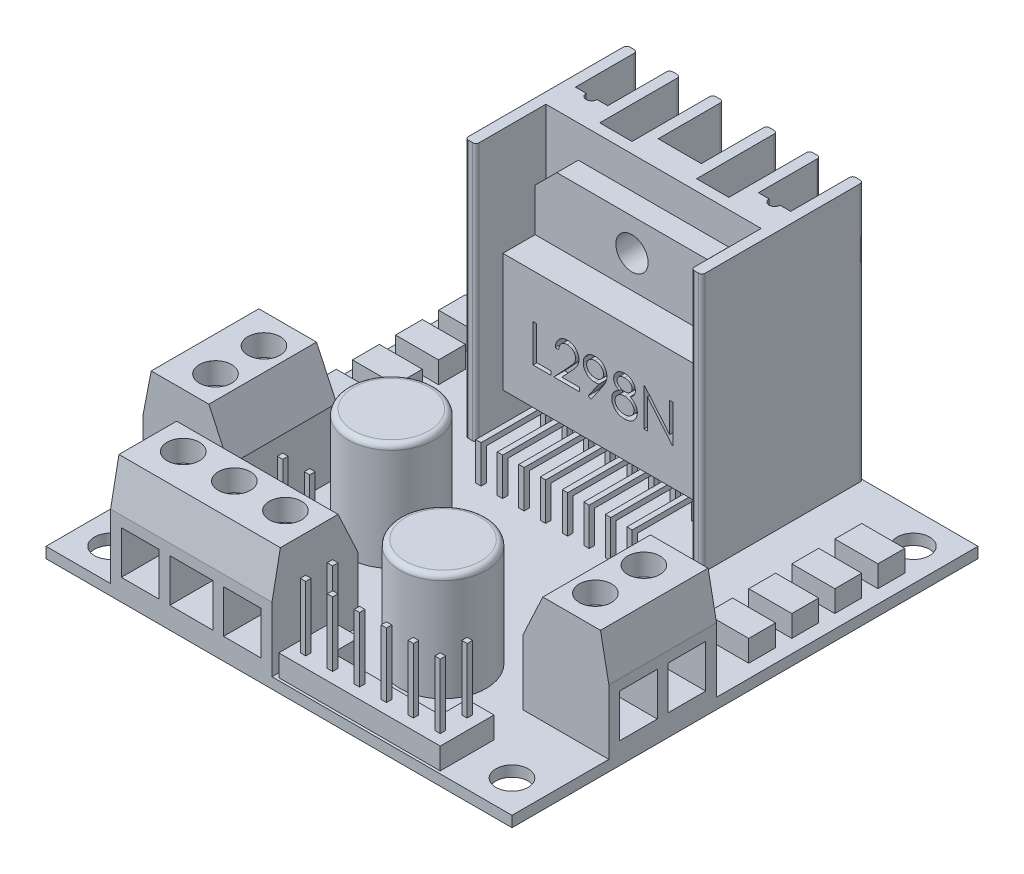
from build123d import *

# Parameters (mm, degrees)
CROQUIS1_W               = 43.3
CROQUIS1_H               = 43.3
CROQUIS1_R               = 1.5
SALIENTE_EXTRUIR1_DEPTH  = 1
CROQUIS2_W               = 1
CROQUIS2_H               = 1
CROQUIS2_H_2             = 6.5
CROQUIS2_W_2             = 3
CROQUIS2_W_3             = 2
CROQUIS2_H_3             = 1.435307759
SALIENTE_EXTRUIR2_DEPTH  = 24
CROQUIS3_W               = 8
CROQUIS3_H               = 10
SALIENTE_EXTRUIR3_DEPTH  = 10
CHAFL_N1_SIZE            = 4
CHAFL_N1_SIZE2           = 1.865230633
CHAFL_N2_SIZE            = 4
CHAFL_N2_SIZE2           = 1.865230633
CHAFL_N3_SIZE            = 4
CHAFL_N3_SIZE2           = 0.777521237
CHAFL_N4_SIZE            = 4
CHAFL_N4_SIZE2           = 0.777521237
CROQUIS4_W               = 15
CROQUIS4_H               = 8
SALIENTE_EXTRUIR4_DEPTH  = 10
CHAFL_N5_SIZE            = 4
CHAFL_N5_SIZE2           = 0.777521237
CHAFL_N6_SIZE            = 4
CHAFL_N6_SIZE2           = 1.865230633
CROQUIS5_W               = 4
CROQUIS5_H               = 2.5
SALIENTE_EXTRUIR5_DEPTH  = 2
CROQUIS6_R               = 4
SALIENTE_EXTRUIR6_DEPTH  = 10
REDONDEO1_R              = 0.5
SALIENTE_EXTRUIR7_DEPTH  = 2
CROQUIS8_W               = 2.5
CROQUIS8_H               = 2.5
SALIENTE_EXTRUIR8_DEPTH  = 2
CROQUIS9_W               = 0.25
CROQUIS9_H               = 0.25
CROQUIS9_H_2             = 0.5
CROQUIS9_W_2             = 0.5
SALIENTE_EXTRUIR9_DEPTH  = 6
CROQUIS10_W              = 0.5
CROQUIS10_H              = 0.5
SALIENTE_EXTRUIR10_DEPTH = 6
CROQUIS11_W              = 9
CROQUIS11_H              = 10
SALIENTE_EXTRUIR11_DEPTH = 5
CORTAR_EXTRUIR1_DEPTH    = 3
CROQUIS13_W              = 0.5
CROQUIS13_H              = 0.5
SALIENTE_EXTRUIR12_DEPTH = 1
CROQUIS14_W              = 0.5
CROQUIS14_H              = 0.5
SALIENTE_EXTRUIR13_DEPTH = 7
CROQUIS15_W              = 0.5
CROQUIS15_H              = 0.5
SALIENTE_EXTRUIR14_DEPTH = 4
CROQUIS16_W              = 0.5
CROQUIS16_H              = 0.5
SALIENTE_EXTRUIR15_DEPTH = 4
CORTAR_EXTRUIR2_DEPTH    = 1
CROQUIS18_R              = 1.5
CORTAR_EXTRUIR3_DEPTH    = 11.5
CROQUIS19_W              = 3.5
CROQUIS19_H              = 4
CORTAR_EXTRUIR4_DEPTH    = 4
CROQUIS20_W              = 3.5
CROQUIS20_H              = 4
CROQUIS20_W_2            = 4
CORTAR_EXTRUIR5_DEPTH    = 4
CROQUIS21_W              = 3.5
CROQUIS21_H              = 4
CORTAR_EXTRUIR6_DEPTH    = 4
CROQUIS22_R              = 1.5
CORTAR_EXTRUIR7_DEPTH    = 2
REDONDEO2_R              = 0.3


with BuildPart() as part:
    # Croquis1 → Saliente-Extruir1 (new body)
    with BuildSketch(Plane(origin=(0, 0, 0), x_dir=(1, 0, 0), z_dir=(0, 1, 0))):
        with Locations((-21.65, -21.65)):
            Rectangle(CROQUIS1_W, CROQUIS1_H)
        with Locations((-40.3, -3)):
            Circle(CROQUIS1_R, mode=Mode.SUBTRACT)
        with Locations((-3, -3)):
            Circle(CROQUIS1_R, mode=Mode.SUBTRACT)
        with Locations((-40.3, -40.3)):
            Circle(CROQUIS1_R, mode=Mode.SUBTRACT)
        with Locations((-3, -40.3)):
            Circle(CROQUIS1_R, mode=Mode.SUBTRACT)
    extrude(amount=SALIENTE_EXTRUIR1_DEPTH)

    # Croquis2 → Saliente-Extruir2 (add)
    with BuildSketch(Plane(origin=(0, 1, 0), x_dir=(-1, 0, 0), z_dir=(0, 1, 0))):
        Polygon((31.65, 5.75316787), (31.65, 0), (32.65, 0), (32.65, 7.5), (31.65, 7.5), align=None)
        with Locations((32.15, 8)):
            Rectangle(CROQUIS2_W, CROQUIS2_H)
        with Locations((32.15, 11.75)):
            Rectangle(CROQUIS2_W, CROQUIS2_H_2)
        with Locations((30.15, 8)):
            Rectangle(CROQUIS2_W_2, CROQUIS2_H)
        with Locations((28.15, 8)):
            Rectangle(CROQUIS2_W, CROQUIS2_H)
        with BuildLine():
            Line((31.65, 7.5), (28.65, 7.5))
            Line((28.65, 7.5), (28.65, 5.75316787))
            Line((28.65, 5.75316787), (29.645779613, 5.75316787))
            ThreePointArc((29.645779613, 5.75316787), (30.15, 6.257388257), (30.654220387, 5.75316787))
            Line((30.654220387, 5.75316787), (31.65, 5.75316787))
            Line((31.65, 5.75316787), (31.65, 7.5))
        make_face()
        with Locations((22.65, 6.782346121)):
            Rectangle(CROQUIS2_W_3, CROQUIS2_H_3)
        with Locations((20.65, 6.782346121)):
            Rectangle(CROQUIS2_W_3, CROQUIS2_H_3)
        Polygon((23.65, 6.064692241), (23.65, 0), (24.65, 0), (24.65, 7.5), (23.65, 7.5), align=None)
        Polygon((27.65, 7.5), (27.65, 0), (28.65, 0), (28.65, 5.75316787), (28.65, 7.5), align=None)
        with Locations((26.15, 8)):
            Rectangle(CROQUIS2_W_2, CROQUIS2_H)
        with Locations((24.15, 8)):
            Rectangle(CROQUIS2_W, CROQUIS2_H)
        with Locations((22.65, 8)):
            Rectangle(CROQUIS2_W_3, CROQUIS2_H)
        with Locations((20.65, 8)):
            Rectangle(CROQUIS2_W_3, CROQUIS2_H)
        with Locations((19.15, 8)):
            Rectangle(CROQUIS2_W, CROQUIS2_H)
        Polygon((18.65, 7.5), (18.65, 0), (19.65, 0), (19.65, 6.064692241), (19.65, 7.5), align=None)
        with Locations((17.15, 8)):
            Rectangle(CROQUIS2_W_2, CROQUIS2_H)
        with Locations((15.15, 8)):
            Rectangle(CROQUIS2_W, CROQUIS2_H)
        with Locations((13.15, 8)):
            Rectangle(CROQUIS2_W_2, CROQUIS2_H)
        with Locations((11.15, 11.75)):
            Rectangle(CROQUIS2_W, CROQUIS2_H_2)
        with Locations((11.15, 8)):
            Rectangle(CROQUIS2_W, CROQUIS2_H)
        Polygon((10.65, 7.5), (10.65, 0), (11.65, 0), (11.65, 5.75316787), (11.65, 7.5), align=None)
        with BuildLine():
            Line((14.65, 7.5), (11.65, 7.5))
            Line((11.65, 7.5), (11.65, 5.75316787))
            Line((11.65, 5.75316787), (12.645779613, 5.75316787))
            ThreePointArc((12.645779613, 5.75316787), (13.15, 6.257388257), (13.654220387, 5.75316787))
            Line((13.654220387, 5.75316787), (14.65, 5.75316787))
            Line((14.65, 5.75316787), (14.65, 7.5))
        make_face()
        Polygon((14.65, 5.75316787), (14.65, 0), (15.65, 0), (15.65, 7.5), (14.65, 7.5), align=None)
    extrude(amount=SALIENTE_EXTRUIR2_DEPTH)

    # Croquis3 → Saliente-Extruir3 (add)
    with BuildSketch(Plane(origin=(0, 1, 0), x_dir=(-1, 0, 0), z_dir=(0, 1, 0))):
        with Locations((39.3, 29.3)):
            Rectangle(CROQUIS3_W, CROQUIS3_H)
        with Locations((4, 29.3)):
            Rectangle(CROQUIS3_W, CROQUIS3_H)
    extrude(amount=SALIENTE_EXTRUIR3_DEPTH)

    # Chaflán1
    chafl_n1_edges = [part.edges().sort_by_distance(p)[0] for p in [
        (-35.3, 11, 29.3),
    ]]
    chafl_n1_side = [part.faces().sort_by_distance(p)[0] for p in [
        (-35.3, 6, 29.3),
    ]]
    chamfer(chafl_n1_edges, length=CHAFL_N1_SIZE, length2=CHAFL_N1_SIZE2, reference=chafl_n1_side[0])

    # Chaflán2
    chafl_n2_edges = [part.edges().sort_by_distance(p)[0] for p in [
        (-8, 11, 29.3),
    ]]
    chafl_n2_side = [part.faces().sort_by_distance(p)[0] for p in [
        (-8, 6, 29.3),
    ]]
    chamfer(chafl_n2_edges, length=CHAFL_N2_SIZE, length2=CHAFL_N2_SIZE2, reference=chafl_n2_side[0])

    # Chaflán3
    chafl_n3_edges = [part.edges().sort_by_distance(p)[0] for p in [
        (0, 11, 29.3),
    ]]
    chafl_n3_side = [part.faces().sort_by_distance(p)[0] for p in [
        (0, 4.338101884, 26.988450803),
    ]]
    chamfer(chafl_n3_edges, length=CHAFL_N3_SIZE, length2=CHAFL_N3_SIZE2, reference=chafl_n3_side[0])

    # Chaflán4
    chafl_n4_edges = [part.edges().sort_by_distance(p)[0] for p in [
        (-43.3, 11, 29.3),
    ]]
    chafl_n4_side = [part.faces().sort_by_distance(p)[0] for p in [
        (-43.3, 4.338101884, 26.988450803),
    ]]
    chamfer(chafl_n4_edges, length=CHAFL_N4_SIZE, length2=CHAFL_N4_SIZE2, reference=chafl_n4_side[0])

    # Croquis4 → Saliente-Extruir4 (add)
    with BuildSketch(Plane(origin=(0, 1, 0), x_dir=(-1, 0, 0), z_dir=(0, 1, 0))):
        with Locations((29.8, 39.3)):
            Rectangle(CROQUIS4_W, CROQUIS4_H)
    extrude(amount=SALIENTE_EXTRUIR4_DEPTH)

    # Chaflán5
    chafl_n5_edges = [part.edges().sort_by_distance(p)[0] for p in [
        (-29.8, 11, 43.3),
    ]]
    chafl_n5_side = [part.faces().sort_by_distance(p)[0] for p in [
        (-27.97436627, 4.767977237, 43.3),
    ]]
    chamfer(chafl_n5_edges, length=CHAFL_N5_SIZE, length2=CHAFL_N5_SIZE2, reference=chafl_n5_side[0])

    # Chaflán6
    chafl_n6_edges = [part.edges().sort_by_distance(p)[0] for p in [
        (-29.8, 11, 35.3),
    ]]
    chafl_n6_side = [part.faces().sort_by_distance(p)[0] for p in [
        (-29.8, 6, 35.3),
    ]]
    chamfer(chafl_n6_edges, length=CHAFL_N6_SIZE, length2=CHAFL_N6_SIZE2, reference=chafl_n6_side[0])

    # Croquis5 → Saliente-Extruir5 (add)
    with BuildSketch(Plane(origin=(0, 1, 0), x_dir=(-1, 0, 0), z_dir=(0, 1, 0))):
        with Locations((40.060783052, 10.814133786)):
            Rectangle(CROQUIS5_W, CROQUIS5_H)
        with Locations((40.060783052, 6.814133786)):
            Rectangle(CROQUIS5_W, CROQUIS5_H)
        with Locations((40.060783052, 14.814133786)):
            Rectangle(CROQUIS5_W, CROQUIS5_H)
        with Locations((40.060783052, 18.814133786)):
            Rectangle(CROQUIS5_W, CROQUIS5_H)
        with Locations((3.239216948, 6.814133786)):
            Rectangle(CROQUIS5_W, CROQUIS5_H)
        with Locations((3.239216948, 10.814133786)):
            Rectangle(CROQUIS5_W, CROQUIS5_H)
        with Locations((3.239216948, 14.814133786)):
            Rectangle(CROQUIS5_W, CROQUIS5_H)
        with Locations((3.239216948, 18.814133786)):
            Rectangle(CROQUIS5_W, CROQUIS5_H)
    extrude(amount=SALIENTE_EXTRUIR5_DEPTH)

    # Croquis6 → Saliente-Extruir6 (add)
    with BuildSketch(Plane(origin=(0, 1, 0), x_dir=(-1, 0, 0), z_dir=(0, 1, 0))):
        with Locations((28.3, 26.210008209)):
            Circle(CROQUIS6_R)
        with Locations((15.406645961, 34.3)):
            Circle(CROQUIS6_R)
    extrude(amount=SALIENTE_EXTRUIR6_DEPTH)

    # Redondeo1
    redondeo1_edges = [part.edges().sort_by_distance(p)[0] for p in [
        (-24.3, 11, 26.210008209),
        (-11.406645961, 11, 34.3),
    ]]
    fillet(redondeo1_edges, radius=REDONDEO1_R)

    # Croquis7 → Saliente-Extruir7 (add)
    with BuildSketch(Plane(origin=(0, 1, 0), x_dir=(-1, 0, 0), z_dir=(0, 1, 0))):
        Polygon((19.407725127, 40.559550143), (19.407725127, 38.059550143), (21.907725127, 38.059550143), (21.907725127, 40.559550143), (21.907725127, 43.059550143), (6.907725127, 43.059550143), (6.907725127, 38.059550143), (9.407725127, 38.059550143), (9.407725127, 40.559550143), align=None)
    extrude(amount=SALIENTE_EXTRUIR7_DEPTH)

    # Croquis8 → Saliente-Extruir8 (add)
    with BuildSketch(Plane(origin=(0, 1, 0), x_dir=(-1, 0, 0), z_dir=(0, 1, 0))):
        with Locations((29.05, 33.05)):
            Rectangle(CROQUIS8_W, CROQUIS8_H)
        with Locations((31.55, 33.05)):
            Rectangle(CROQUIS8_W, CROQUIS8_H)
    extrude(amount=SALIENTE_EXTRUIR8_DEPTH)

    # Croquis9 → Saliente-Extruir9 (add)
    with BuildSketch(Plane(origin=(0, 3, 0), x_dir=(-1, 0, 0), z_dir=(0, 1, 0))):
        with Locations((20.532725127, 41.934550143)):
            Rectangle(CROQUIS9_W, CROQUIS9_H)
        with Locations((20.532725127, 41.684550143)):
            Rectangle(CROQUIS9_W, CROQUIS9_H)
        with Locations((20.782725127, 41.934550143)):
            Rectangle(CROQUIS9_W, CROQUIS9_H)
        with Locations((20.782725127, 41.684550143)):
            Rectangle(CROQUIS9_W, CROQUIS9_H)
        with Locations((20.532725127, 39.309550143)):
            Rectangle(CROQUIS9_W, CROQUIS9_H_2)
        with Locations((20.782725127, 39.309550143)):
            Rectangle(CROQUIS9_W, CROQUIS9_H_2)
        with Locations((18.157725127, 41.684550143)):
            Rectangle(CROQUIS9_W_2, CROQUIS9_H)
        with Locations((18.157725127, 41.934550143)):
            Rectangle(CROQUIS9_W_2, CROQUIS9_H)
        with Locations((15.657725127, 41.684550143)):
            Rectangle(CROQUIS9_W_2, CROQUIS9_H)
        with Locations((15.657725127, 41.934550143)):
            Rectangle(CROQUIS9_W_2, CROQUIS9_H)
        with Locations((13.157725127, 41.934550143)):
            Rectangle(CROQUIS9_W_2, CROQUIS9_H)
        with Locations((13.157725127, 41.684550143)):
            Rectangle(CROQUIS9_W_2, CROQUIS9_H)
        with Locations((10.657725127, 41.934550143)):
            Rectangle(CROQUIS9_W_2, CROQUIS9_H)
        with Locations((10.657725127, 41.684550143)):
            Rectangle(CROQUIS9_W_2, CROQUIS9_H)
        with Locations((8.032725127, 41.934550143)):
            Rectangle(CROQUIS9_W, CROQUIS9_H)
        with Locations((8.032725127, 41.684550143)):
            Rectangle(CROQUIS9_W, CROQUIS9_H)
        with Locations((8.282725127, 41.684550143)):
            Rectangle(CROQUIS9_W, CROQUIS9_H)
        with Locations((8.282725127, 41.934550143)):
            Rectangle(CROQUIS9_W, CROQUIS9_H)
        with Locations((8.032725127, 39.309550143)):
            Rectangle(CROQUIS9_W, CROQUIS9_H_2)
        with Locations((8.282725127, 39.309550143)):
            Rectangle(CROQUIS9_W, CROQUIS9_H_2)
    extrude(amount=SALIENTE_EXTRUIR9_DEPTH)

    # Croquis10 → Saliente-Extruir10 (add)
    with BuildSketch(Plane(origin=(0, 3, 0), x_dir=(1, 0, 0), z_dir=(0, 1, 0))):
        with Locations((-29.05, -33.05)):
            Rectangle(CROQUIS10_W, CROQUIS10_H)
        with Locations((-31.55, -33.05)):
            Rectangle(CROQUIS10_W, CROQUIS10_H)
    extrude(amount=SALIENTE_EXTRUIR10_DEPTH)

    # Croquis11 → Saliente-Extruir11 (add)
    with BuildSketch(Plane.XY.offset(8.5)):
        Polygon((-21.65, 15), (-21.65, 22), (-28.637466442, 22), (-30.65, 19.987466442), (-30.65, 15), align=None)
        Polygon((-14.662533558, 22), (-21.65, 22), (-21.65, 15), (-12.65, 15), (-12.65, 19.987466442), align=None)
        with Locations((-26.15, 10)):
            Rectangle(CROQUIS11_W, CROQUIS11_H)
        with Locations((-17.15, 10)):
            Rectangle(CROQUIS11_W, CROQUIS11_H)
    extrude(amount=SALIENTE_EXTRUIR11_DEPTH)

    # Croquis12 → Cortar-Extruir1 (cut)
    with BuildSketch(Plane.XY.offset(13.5)):
        Polygon((-14.662533558, 22), (-28.637466442, 22), (-30.65, 19.987466442), (-30.65, 16), (-12.65, 16), (-12.65, 19.987466442), align=None)
    extrude(amount=-CORTAR_EXTRUIR1_DEPTH, mode=Mode.SUBTRACT)

    # Croquis13 → Saliente-Extruir12 (add)
    with BuildSketch(Plane.XZ.offset(-5)):
        with Locations((-28.173070454, 11)):
            Rectangle(CROQUIS13_W, CROQUIS13_H)
        with Locations((-29.173070454, 11)):
            Rectangle(CROQUIS13_W, CROQUIS13_H)
        with Locations((-27.173070454, 11)):
            Rectangle(CROQUIS13_W, CROQUIS13_H)
        with Locations((-26.173070454, 11)):
            Rectangle(CROQUIS13_W, CROQUIS13_H)
        with Locations((-25.173070454, 11)):
            Rectangle(CROQUIS13_W, CROQUIS13_H)
        with Locations((-24.173070454, 11)):
            Rectangle(CROQUIS13_W, CROQUIS13_H)
        with Locations((-23.173070454, 11)):
            Rectangle(CROQUIS13_W, CROQUIS13_H)
        with Locations((-22.173070454, 11)):
            Rectangle(CROQUIS13_W, CROQUIS13_H)
        with Locations((-21.126929546, 11)):
            Rectangle(CROQUIS13_W, CROQUIS13_H)
        with Locations((-20.126929546, 11)):
            Rectangle(CROQUIS13_W, CROQUIS13_H)
        with Locations((-19.126929546, 11)):
            Rectangle(CROQUIS13_W, CROQUIS13_H)
        with Locations((-18.126929546, 11)):
            Rectangle(CROQUIS13_W, CROQUIS13_H)
        with Locations((-17.126929546, 11)):
            Rectangle(CROQUIS13_W, CROQUIS13_H)
        with Locations((-16.126929546, 11)):
            Rectangle(CROQUIS13_W, CROQUIS13_H)
        with Locations((-15.126929546, 11)):
            Rectangle(CROQUIS13_W, CROQUIS13_H)
        with Locations((-14.126929546, 11)):
            Rectangle(CROQUIS13_W, CROQUIS13_H)
    extrude(amount=SALIENTE_EXTRUIR12_DEPTH)

    # Croquis14 → Saliente-Extruir13 (add)
    with BuildSketch(Plane.XY.offset(11.25)):
        with Locations((-14.126929546, 4.25)):
            Rectangle(CROQUIS14_W, CROQUIS14_H)
        with Locations((-16.126929546, 4.25)):
            Rectangle(CROQUIS14_W, CROQUIS14_H)
        with Locations((-18.126929546, 4.25)):
            Rectangle(CROQUIS14_W, CROQUIS14_H)
        with Locations((-20.126929546, 4.25)):
            Rectangle(CROQUIS14_W, CROQUIS14_H)
        with Locations((-22.173070454, 4.25)):
            Rectangle(CROQUIS14_W, CROQUIS14_H)
        with Locations((-24.173070454, 4.25)):
            Rectangle(CROQUIS14_W, CROQUIS14_H)
        with Locations((-26.173070454, 4.25)):
            Rectangle(CROQUIS14_W, CROQUIS14_H)
        with Locations((-28.173070454, 4.25)):
            Rectangle(CROQUIS14_W, CROQUIS14_H)
    extrude(amount=SALIENTE_EXTRUIR13_DEPTH)

    # Croquis15 → Saliente-Extruir14 (add)
    with BuildSketch(Plane.XZ):
        with Locations((-28.173070454, 18)):
            Rectangle(CROQUIS15_W, CROQUIS15_H)
        with Locations((-26.173070454, 18)):
            Rectangle(CROQUIS15_W, CROQUIS15_H)
        with Locations((-24.173070454, 18)):
            Rectangle(CROQUIS15_W, CROQUIS15_H)
        with Locations((-22.173070454, 18)):
            Rectangle(CROQUIS15_W, CROQUIS15_H)
        with Locations((-20.126929546, 18)):
            Rectangle(CROQUIS15_W, CROQUIS15_H)
        with Locations((-18.126929546, 18)):
            Rectangle(CROQUIS15_W, CROQUIS15_H)
        with Locations((-16.126929546, 18)):
            Rectangle(CROQUIS15_W, CROQUIS15_H)
        with Locations((-14.126929546, 18)):
            Rectangle(CROQUIS15_W, CROQUIS15_H)
    extrude(amount=-SALIENTE_EXTRUIR14_DEPTH)

    # Croquis16 → Saliente-Extruir15 (add)
    with BuildSketch(Plane.XZ):
        with Locations((-29.173070454, 11)):
            Rectangle(CROQUIS16_W, CROQUIS16_H)
        with Locations((-27.173070454, 11)):
            Rectangle(CROQUIS16_W, CROQUIS16_H)
        with Locations((-25.173070454, 11)):
            Rectangle(CROQUIS16_W, CROQUIS16_H)
        with Locations((-23.173070454, 11)):
            Rectangle(CROQUIS16_W, CROQUIS16_H)
        with Locations((-21.126929546, 11)):
            Rectangle(CROQUIS16_W, CROQUIS16_H)
        with Locations((-19.126929546, 11)):
            Rectangle(CROQUIS16_W, CROQUIS16_H)
        with Locations((-17.126929546, 11)):
            Rectangle(CROQUIS16_W, CROQUIS16_H)
        with Locations((-15.126929546, 11)):
            Rectangle(CROQUIS16_W, CROQUIS16_H)
    extrude(amount=-SALIENTE_EXTRUIR15_DEPTH)

    # Croquis17 → Cortar-Extruir2 (cut)
    with BuildSketch(Plane.XY.offset(13.5)):
        Polygon((-27.846931762, 11.915865738), (-27.532829198, 11.915865738), (-27.532829198, 8.774840097), (-26.186675351, 8.774840097), (-26.186675351, 8.415865738), (-27.846931762, 8.415865738), align=None)
        with BuildLine():
            Line((-25.468726633, 10.838942661), (-25.782829198, 10.838942661))
            add(Edge.make_bspline(
                [(-25.782829198, 10.838942661), (-25.780782045, 10.880613549), (-25.77676149, 10.962454063), (-25.757933201, 11.08177797), (-25.730992324, 11.195832768), (-25.69290087, 11.303702682), (-25.645594592, 11.40634149), (-25.588864565, 11.503341505), (-25.521670714, 11.594332694), (-25.44546398, 11.678471537), (-25.362695341, 11.755659108), (-25.273389402, 11.822314351), (-25.179544374, 11.878632022), (-25.081444976, 11.925713264), (-24.977984412, 11.96105311), (-24.870101554, 11.98727475), (-24.757322418, 12.003051095), (-24.680482396, 12.004746881), (-24.641402915, 12.005609328)],
                knots=[0, 0, 0, 0, 0.000125083, 0.00024566, 0.000361805, 0.000476223, 0.000588214, 0.000700404, 0.000812728, 0.00092691, 0.001040529, 0.001151727, 0.001260545, 0.001368429, 0.001477521, 0.001587884, 0.001701119, 0.00181831, 0.00181831, 0.00181831, 0.00181831], degree=3))
            add(Edge.make_bspline(
                [(-24.641402915, 12.005609328), (-24.603024841, 12.004710871), (-24.527613297, 12.002945436), (-24.417551282, 11.987784407), (-24.312773988, 11.964038815), (-24.213486221, 11.930723399), (-24.120480157, 11.885938972), (-24.033057112, 11.832141433), (-23.950176301, 11.769921602), (-23.875569518, 11.696667788), (-23.807061439, 11.618465404), (-23.747959183, 11.5349775), (-23.69734602, 11.448748214), (-23.65515834, 11.359120013), (-23.624102201, 11.265248985), (-23.600523993, 11.168501782), (-23.587196579, 11.067876971), (-23.585151156, 10.999770415), (-23.584111249, 10.965144584)],
                knots=[0, 0, 0, 0, 0.000115089, 0.000226145, 0.000332614, 0.000437044, 0.000539592, 0.000641561, 0.000744629, 0.00084975, 0.000954621, 0.001056175, 0.001156101, 0.001254284, 0.001352726, 0.001452208, 0.001552655, 0.001656537, 0.001656537, 0.001656537, 0.001656537], degree=3))
            add(Edge.make_bspline(
                [(-23.584111249, 10.965144584), (-23.585804512, 10.916396749), (-23.589161323, 10.819756536), (-23.6178757, 10.677741673), (-23.662722211, 10.540148254), (-23.716719568, 10.429410952), (-23.771192012, 10.340177458), (-23.820279519, 10.266708753), (-23.87774433, 10.187603285), (-23.944422828, 10.103125947), (-24.0189357, 10.012615042), (-24.101957864, 9.916125247), (-24.194081346, 9.814653477), (-24.258739846, 9.745347876), (-24.292244262, 9.709435449)],
                knots=[0, 0, 0, 0, 0.000146118, 0.000289672, 0.0004329, 0.00057934, 0.000657978, 0.000746456, 0.000844345, 0.000951219, 0.001069268, 0.00119604, 0.001333047, 0.001480391, 0.001480391, 0.001480391, 0.001480391], degree=3))
            Line((-24.292244262, 9.709435449), (-25.167945383, 8.774840097))
            Line((-25.167945383, 8.774840097), (-23.539239454, 8.774840097))
            Line((-23.539239454, 8.774840097), (-23.539239454, 8.415865738))
            Line((-23.539239454, 8.415865738), (-25.917444582, 8.415865738))
            Line((-25.917444582, 8.415865738), (-24.560072787, 9.864383366))
            add(Edge.make_bspline(
                [(-24.560072787, 9.864383366), (-24.5270249, 9.898881673), (-24.463546673, 9.965145859), (-24.373764097, 10.061888819), (-24.293125108, 10.15163836), (-24.221107715, 10.234224909), (-24.15927421, 10.310856476), (-24.104401978, 10.37905118), (-24.060436387, 10.44180563), (-24.012720991, 10.514546244), (-23.96650701, 10.603358561), (-23.926794654, 10.711892251), (-23.902579806, 10.823619503), (-23.89967497, 10.89912154), (-23.898213813, 10.937099712)],
                knots=[0, 0, 0, 0, 0.000143319, 0.000275286, 0.00039593, 0.000505287, 0.000603949, 0.000691331, 0.000767782, 0.00083371, 0.000952247, 0.001067137, 0.001179618, 0.001293462, 0.001293462, 0.001293462, 0.001293462], degree=3))
            add(Edge.make_bspline(
                [(-23.898213813, 10.937099712), (-23.898849555, 10.960981111), (-23.900102481, 11.008046761), (-23.911160179, 11.07705252), (-23.927870685, 11.143617334), (-23.951815943, 11.207945953), (-23.983422683, 11.269391605), (-24.021896063, 11.328029085), (-24.066286126, 11.38471805), (-24.117637396, 11.437871349), (-24.174048915, 11.486552554), (-24.233643165, 11.529676639), (-24.296693269, 11.56571575), (-24.362933391, 11.595259247), (-24.432178861, 11.618434629), (-24.504563606, 11.634493208), (-24.579887622, 11.644575692), (-24.631321118, 11.645939864), (-24.657528717, 11.646634969)],
                knots=[0, 0, 0, 0, 7.16e-05, 0.00014111, 0.00020913, 0.00027724, 0.000346538, 0.000415963, 0.000487357, 0.000562233, 0.000637292, 0.000710646, 0.000782564, 0.000854749, 0.000927915, 0.001001225, 0.001076884, 0.001155488, 0.001155488, 0.001155488, 0.001155488], degree=3))
            add(Edge.make_bspline(
                [(-24.657528717, 11.646634969), (-24.68489955, 11.645919936), (-24.738651346, 11.644515731), (-24.817570379, 11.634693067), (-24.892856156, 11.617747227), (-24.964698059, 11.594570552), (-25.033217645, 11.565112004), (-25.098081689, 11.528420259), (-25.159144578, 11.484636766), (-25.216521102, 11.434996209), (-25.269385081, 11.379728608), (-25.315831957, 11.318118645), (-25.356415971, 11.25129123), (-25.391825204, 11.179426679), (-25.420580894, 11.101872899), (-25.442554045, 11.018905194), (-25.459940891, 10.930883813), (-25.465749412, 10.870098728), (-25.468726633, 10.838942661)],
                knots=[0, 0, 0, 0, 8.2106e-05, 0.000161243, 0.000238127, 0.000313291, 0.000387401, 0.000461495, 0.000536397, 0.000612445, 0.000688819, 0.000765383, 0.000843422, 0.000923066, 0.001005373, 0.001091093, 0.001180334, 0.001274175, 0.001274175, 0.001274175, 0.001274175], degree=3))
        make_face()
        with BuildLine():
            Line((-22.462316377, 8.326122148), (-22.71331798, 8.500701475))
            Line((-22.71331798, 8.500701475), (-21.740160928, 9.923277597))
            add(Edge.make_bspline(
                [(-21.740160928, 9.923277597), (-21.802251664, 9.915684534), (-21.924511784, 9.900733369), (-22.047648886, 9.897986714), (-22.108249871, 9.896634969)],
                knots=[0, 0, 0, 0, 0.000187529, 0.000369255, 0.000369255, 0.000369255, 0.000369255], degree=3))
            add(Edge.make_bspline(
                [(-22.108249871, 9.896634969), (-22.144991918, 9.897576045), (-22.217113345, 9.899423296), (-22.323144998, 9.914065104), (-22.425030558, 9.936615232), (-22.522499914, 9.970263987), (-22.615919419, 10.012082196), (-22.705085133, 10.06393921), (-22.789877023, 10.124945501), (-22.869384433, 10.194778493), (-22.941696172, 10.271456545), (-23.00611947, 10.352612188), (-23.059660602, 10.439188159), (-23.104137187, 10.529418378), (-23.137867641, 10.624599729), (-23.162430178, 10.723649129), (-23.177552532, 10.827260771), (-23.179351628, 10.897785902), (-23.180265095, 10.933594103)],
                knots=[0, 0, 0, 0, 0.000110185, 0.000216284, 0.000320547, 0.000422759, 0.000525058, 0.000627155, 0.000731643, 0.000837964, 0.0009441, 0.00104747, 0.001148247, 0.001248901, 0.001348697, 0.001450555, 0.001554666, 0.00166205, 0.00166205, 0.00166205, 0.00166205], degree=3))
            add(Edge.make_bspline(
                [(-23.180265095, 10.933594103), (-23.17853066, 10.982562756), (-23.175126317, 11.078678288), (-23.147727799, 11.219112057), (-23.10266746, 11.3518986), (-23.039839083, 11.476688794), (-22.960704362, 11.591687533), (-22.865595772, 11.695296142), (-22.755091807, 11.786040996), (-22.631709788, 11.864045074), (-22.498356768, 11.926780071), (-22.358688109, 11.973019371), (-22.213773989, 12.000218119), (-22.115606319, 12.00380398), (-22.066182563, 12.005609328)],
                knots=[0, 0, 0, 0, 0.000146818, 0.000288173, 0.000427413, 0.000566316, 0.000705952, 0.000844895, 0.000986821, 0.001133677, 0.001281714, 0.001427825, 0.001574003, 0.00172222, 0.00172222, 0.00172222, 0.00172222], degree=3))
            add(Edge.make_bspline(
                [(-22.066182563, 12.005609328), (-22.017694143, 12.003779165), (-21.921885596, 12.000162935), (-21.78099659, 11.973678966), (-21.646055573, 11.929042293), (-21.517810586, 11.867357729), (-21.399071174, 11.790036822), (-21.292295363, 11.697902298), (-21.199919824, 11.590896771), (-21.122095943, 11.471608281), (-21.059625903, 11.343441299), (-21.01455362, 11.209657377), (-20.986807981, 11.071218656), (-20.983311654, 10.977424181), (-20.981547146, 10.930088494)],
                knots=[0, 0, 0, 0, 0.000145418, 0.000287333, 0.000428343, 0.000570713, 0.000713061, 0.00085223, 0.000992387, 0.001135706, 0.001278381, 0.001418948, 0.001558239, 0.001700158, 0.001700158, 0.001700158, 0.001700158], degree=3))
            add(Edge.make_bspline(
                [(-20.981547146, 10.930088494), (-20.982725555, 10.893344727), (-20.985115663, 10.818819186), (-21.00185197, 10.705588844), (-21.030272155, 10.590137614), (-21.062523854, 10.492416018), (-21.093656022, 10.411707569), (-21.122957153, 10.347955989), (-21.155469307, 10.280854725), (-21.193388072, 10.211107387), (-21.234150369, 10.137824852), (-21.280209646, 10.061742137), (-21.330515217, 9.982757144), (-21.366344937, 9.929510056), (-21.384692178, 9.902243943)],
                knots=[0, 0, 0, 0, 0.000110219, 0.000223552, 0.000342587, 0.000466527, 0.000532018, 0.000601997, 0.000676938, 0.00075567, 0.000840114, 0.000928491, 0.001022434, 0.001121023, 0.001121023, 0.001121023, 0.001121023], degree=3))
            Line((-21.384692178, 9.902243943), (-22.462316377, 8.326122148))
        make_face()
        with BuildLine():
            add(Edge.make_bspline(
                [(-22.050056762, 10.255609328), (-22.022222748, 10.256369711), (-21.968039384, 10.25784992), (-21.888662085, 10.266859162), (-21.813737882, 10.282833148), (-21.743066633, 10.30575286), (-21.675939731, 10.333409529), (-21.613423403, 10.368621515), (-21.555465327, 10.41063815), (-21.5016774, 10.457848166), (-21.453913401, 10.510298749), (-21.41137037, 10.565195856), (-21.375209802, 10.622780466), (-21.346646525, 10.683773728), (-21.32316195, 10.746690937), (-21.306943938, 10.812545292), (-21.297959605, 10.880993693), (-21.29642803, 10.927492351), (-21.29564971, 10.951122148)],
                knots=[0, 0, 0, 0, 8.3507e-05, 0.00016256, 0.000239294, 0.000312908, 0.000385178, 0.000456751, 0.000527578, 0.000599603, 0.000671055, 0.000740051, 0.000807755, 0.000874553, 0.000941763, 0.001008931, 0.001077548, 0.001148448, 0.001148448, 0.001148448, 0.001148448], degree=3))
            add(Edge.make_bspline(
                [(-21.29564971, 10.951122148), (-21.29631938, 10.974761813), (-21.297639045, 11.021346673), (-21.308226344, 11.089896413), (-21.326851568, 11.155589674), (-21.351842052, 11.218786104), (-21.38476229, 11.278966476), (-21.424265776, 11.336886348), (-21.471198226, 11.392178475), (-21.525200792, 11.443542459), (-21.583435345, 11.490890358), (-21.645495845, 11.532676434), (-21.710870761, 11.567697631), (-21.779161251, 11.5965966), (-21.8505096, 11.619148376), (-21.924873588, 11.635365741), (-22.002628994, 11.644337495), (-22.05541028, 11.64585939), (-22.082308364, 11.646634969)],
                knots=[0, 0, 0, 0, 7.09e-05, 0.000139717, 0.000207422, 0.000275384, 0.000343146, 0.000412766, 0.000485392, 0.000560268, 0.000636041, 0.000710323, 0.000784354, 0.000858188, 0.000932471, 0.001008519, 0.001086179, 0.001166885, 0.001166885, 0.001166885, 0.001166885], degree=3))
            add(Edge.make_bspline(
                [(-22.082308364, 11.646634969), (-22.108972518, 11.645858137), (-22.161287367, 11.644334), (-22.238351526, 11.635382794), (-22.312212694, 11.61903931), (-22.383354314, 11.596607046), (-22.451642775, 11.567695475), (-22.517014608, 11.532674599), (-22.579089624, 11.490899977), (-22.637268345, 11.443505204), (-22.691366267, 11.392417558), (-22.737491796, 11.336644129), (-22.777085688, 11.278996605), (-22.809960691, 11.218778097), (-22.834963208, 11.155591811), (-22.85358521, 11.089895834), (-22.864173375, 11.021346824), (-22.865492922, 10.974761864), (-22.866162531, 10.951122148)],
                knots=[0, 0, 0, 0, 8.0005e-05, 0.000156969, 0.000232332, 0.000306614, 0.000380449, 0.000454479, 0.000528762, 0.000604535, 0.000679411, 0.000751586, 0.000821205, 0.000888968, 0.00095693, 0.001024634, 0.001093451, 0.001164351, 0.001164351, 0.001164351, 0.001164351], degree=3))
            add(Edge.make_bspline(
                [(-22.866162531, 10.951122148), (-22.865556605, 10.927473949), (-22.864361608, 10.880835373), (-22.852833818, 10.81230898), (-22.833555538, 10.746620786), (-22.807736147, 10.683132079), (-22.773734557, 10.622460221), (-22.732010709, 10.564892859), (-22.683105163, 10.509777409), (-22.627671676, 10.457970197), (-22.567003515, 10.410418022), (-22.502206769, 10.36888764), (-22.434396932, 10.333815195), (-22.363335301, 10.305673811), (-22.289548501, 10.283062148), (-22.21237337, 10.266888603), (-22.132065132, 10.257936336), (-22.07765515, 10.256392439), (-22.050056762, 10.255609328)],
                knots=[0, 0, 0, 0, 7.09e-05, 0.000139828, 0.000207725, 0.00027595, 0.000345002, 0.000415829, 0.000488844, 0.000565728, 0.000643147, 0.000719775, 0.000796287, 0.0008718, 0.000948761, 0.001027552, 0.001107998, 0.001190805, 0.001190805, 0.001190805, 0.001190805], degree=3))
        make_face(mode=Mode.SUBTRACT)
        with BuildLine():
            add(Edge.make_bspline(
                [(-18.831206601, 10.365685449), (-18.802558054, 10.350747493), (-18.74668382, 10.321613491), (-18.667106611, 10.274702663), (-18.59438161, 10.225261698), (-18.526491048, 10.175625839), (-18.464627698, 10.123894187), (-18.409483285, 10.069861031), (-18.359695665, 10.014875086), (-18.316268881, 9.958005246), (-18.278072044, 9.899402596), (-18.245059909, 9.838913323), (-18.216842706, 9.77666999), (-18.194479767, 9.71199316), (-18.176057976, 9.645832898), (-18.163382371, 9.577334916), (-18.156565453, 9.506950575), (-18.155276639, 9.459382274), (-18.154624069, 9.435296828)],
                knots=[0, 0, 0, 0, 9.692e-05, 0.000189026, 0.000276921, 0.000360637, 0.000441251, 0.000518597, 0.000592078, 0.000663595, 0.000733021, 0.000801734, 0.000870147, 0.000937778, 0.001006834, 0.001076004, 0.001146466, 0.001218736, 0.001218736, 0.001218736, 0.001218736], degree=3))
            add(Edge.make_bspline(
                [(-18.154624069, 9.435296828), (-18.15539549, 9.401599095), (-18.156922421, 9.334898638), (-18.170222405, 9.236452527), (-18.190135383, 9.140840745), (-18.219214895, 9.048084254), (-18.256928286, 8.958694881), (-18.303405122, 8.872596107), (-18.356016327, 8.788376798), (-18.398268567, 8.736557396), (-18.419648108, 8.710336892)],
                knots=[0, 0, 0, 0, 0.000101049, 0.000200014, 0.00029751, 0.000393751, 0.000491154, 0.000588073, 0.000687071, 0.000788472, 0.000788472, 0.000788472, 0.000788472], degree=3))
            add(Edge.make_bspline(
                [(-18.419648108, 8.710336892), (-18.447484582, 8.679743118), (-18.502813548, 8.618933625), (-18.597596475, 8.539982815), (-18.701618359, 8.473633421), (-18.814476692, 8.419561526), (-18.935869793, 8.377475667), (-19.065771798, 8.347233149), (-19.204435951, 8.32991072), (-19.299741422, 8.327406731), (-19.348634486, 8.326122148)],
                knots=[0, 0, 0, 0, 0.000123978, 0.000246423, 0.000368759, 0.000493253, 0.000620972, 0.000753455, 0.000892683, 0.001039354, 0.001039354, 0.001039354, 0.001039354], degree=3))
            add(Edge.make_bspline(
                [(-19.348634486, 8.326122148), (-19.395647875, 8.327274626), (-19.487131154, 8.329517231), (-19.620289031, 8.344711663), (-19.744412101, 8.371339529), (-19.860222069, 8.407784139), (-19.967020763, 8.455194367), (-20.064503864, 8.514202776), (-20.154077836, 8.582434218), (-20.23302431, 8.661848296), (-20.303112753, 8.746906168), (-20.364680807, 8.834657778), (-20.415854885, 8.925111136), (-20.45918198, 9.016917503), (-20.492350003, 9.111363657), (-20.515322213, 9.20796367), (-20.529911527, 9.306548813), (-20.531852662, 9.373080466), (-20.532829198, 9.406550834)],
                knots=[0, 0, 0, 0, 0.000141037, 0.000274444, 0.00040137, 0.000521327, 0.000638076, 0.000750983, 0.00086247, 0.000975011, 0.001086056, 0.001192834, 0.001296147, 0.001397463, 0.001497025, 0.001595826, 0.001694979, 0.00179536, 0.00179536, 0.00179536, 0.00179536], degree=3))
            add(Edge.make_bspline(
                [(-20.532829198, 9.406550834), (-20.532251316, 9.431110026), (-20.53110922, 9.479647658), (-20.523204371, 9.551356986), (-20.51049591, 9.621153121), (-20.493236453, 9.689293865), (-20.469845427, 9.755283137), (-20.441603294, 9.819433611), (-20.408671341, 9.88181771), (-20.370590176, 9.942776591), (-20.326288152, 10.001456103), (-20.276124502, 10.058852098), (-20.219096634, 10.114073965), (-20.155838975, 10.16779639), (-20.087074435, 10.220972364), (-20.011016905, 10.270728092), (-19.929682637, 10.320586057), (-19.871877231, 10.350394382), (-19.84222423, 10.365685449)],
                knots=[0, 0, 0, 0, 7.3671e-05, 0.0001456, 0.000216149, 0.000286381, 0.000356229, 0.000425923, 0.00049649, 0.000567687, 0.000641305, 0.000716824, 0.000796154, 0.000879197, 0.00096572, 0.001056725, 0.001151716, 0.001251771, 0.001251771, 0.001251771, 0.001251771], degree=3))
            add(Edge.make_bspline(
                [(-19.84222423, 10.365685449), (-19.882815604, 10.387820218), (-19.961411867, 10.430679326), (-20.065481308, 10.509426132), (-20.154871932, 10.594713947), (-20.227126649, 10.688343741), (-20.283998877, 10.787390616), (-20.323017482, 10.891234868), (-20.349413966, 10.997950982), (-20.352028793, 11.070857178), (-20.353342018, 11.107472308)],
                knots=[0, 0, 0, 0, 0.000138535, 0.000268243, 0.000390218, 0.00050816, 0.000621822, 0.000731457, 0.000840134, 0.00094978, 0.00094978, 0.00094978, 0.00094978], degree=3))
            add(Edge.make_bspline(
                [(-20.353342018, 11.107472308), (-20.351706594, 11.144769867), (-20.348419106, 11.219744464), (-20.321835786, 11.331350587), (-20.278515719, 11.440967152), (-20.219594722, 11.548062865), (-20.146207506, 11.64901308), (-20.05816096, 11.739554026), (-19.957557663, 11.818865508), (-19.844899796, 11.885441681), (-19.723663561, 11.93962534), (-19.595747837, 11.977003763), (-19.463381344, 12.001439879), (-19.373283624, 12.004206534), (-19.327600832, 12.005609328)],
                knots=[0, 0, 0, 0, 0.000111795, 0.000224728, 0.000342168, 0.000464543, 0.000590474, 0.000715423, 0.000842224, 0.000973648, 0.001107055, 0.001239485, 0.001372621, 0.001509557, 0.001509557, 0.001509557, 0.001509557], degree=3))
            add(Edge.make_bspline(
                [(-19.327600832, 12.005609328), (-19.283097017, 12.004162985), (-19.195340564, 12.001310961), (-19.066345936, 11.977524083), (-18.942921059, 11.937794563), (-18.82549156, 11.88389734), (-18.716159693, 11.817510399), (-18.619557383, 11.737109525), (-18.534224801, 11.646967974), (-18.463640407, 11.546048371), (-18.405477518, 11.439364177), (-18.364976617, 11.327741656), (-18.339024643, 11.213592597), (-18.335751278, 11.136354593), (-18.334111249, 11.097656603)],
                knots=[0, 0, 0, 0, 0.000133436, 0.000263121, 0.000391946, 0.000521517, 0.000649943, 0.000774455, 0.000897469, 0.001021193, 0.0011429, 0.001260905, 0.001376422, 0.001492413, 0.001492413, 0.001492413, 0.001492413], degree=3))
            add(Edge.make_bspline(
                [(-18.334111249, 11.097656603), (-18.335545809, 11.059679939), (-18.338363205, 10.98509593), (-18.362063145, 10.87636941), (-18.401976458, 10.774547371), (-18.456470621, 10.678474419), (-18.527496109, 10.589892921), (-18.614104842, 10.507676451), (-18.71560632, 10.431149623), (-18.791867206, 10.387963258), (-18.831206601, 10.365685449)],
                knots=[0, 0, 0, 0, 0.000113843, 0.000223582, 0.000331909, 0.000440874, 0.000553657, 0.00067118, 0.000798364, 0.000933876, 0.000933876, 0.000933876, 0.000933876], degree=3))
        make_face()
        with BuildLine():
            add(Edge.make_bspline(
                [(-19.345128877, 11.646634969), (-19.369679683, 11.645983528), (-19.417711794, 11.644709026), (-19.488140465, 11.638050389), (-19.555112832, 11.625097172), (-19.619328633, 11.60785846), (-19.679907445, 11.584570472), (-19.737672, 11.557175463), (-19.79163919, 11.523869397), (-19.842460493, 11.486508199), (-19.888211267, 11.445415293), (-19.928815819, 11.402601575), (-19.962543933, 11.357226182), (-19.991185043, 11.310417823), (-20.01196656, 11.260787247), (-20.027530864, 11.20985607), (-20.038052255, 11.156980686), (-20.038840645, 11.120844176), (-20.039239454, 11.102564456)],
                knots=[0, 0, 0, 0, 7.3671e-05, 0.000144133, 0.000211925, 0.000278091, 0.000343329, 0.00040636, 0.000469609, 0.000533272, 0.00059534, 0.000653874, 0.000709964, 0.000764674, 0.00081807, 0.000870854, 0.000924347, 0.000979106, 0.000979106, 0.000979106, 0.000979106], degree=3))
            add(Edge.make_bspline(
                [(-20.039239454, 11.102564456), (-20.038552087, 11.084283946), (-20.037193751, 11.048159033), (-20.026688623, 10.994813167), (-20.011031768, 10.942391531), (-19.986381107, 10.89214062), (-19.956814749, 10.84231726), (-19.920323273, 10.794166674), (-19.876834245, 10.74752129), (-19.827806804, 10.702777848), (-19.774395267, 10.660879085), (-19.717811223, 10.624505904), (-19.658764832, 10.594071793), (-19.597862763, 10.568742388), (-19.534484315, 10.549052451), (-19.469017842, 10.535083805), (-19.40145234, 10.526401808), (-19.355671759, 10.525364787), (-19.332508685, 10.524840097)],
                knots=[0, 0, 0, 0, 5.48e-05, 0.000108292, 0.000162623, 0.00021845, 0.000275685, 0.000336262, 0.000399273, 0.000466763, 0.000535204, 0.00060269, 0.000668229, 0.000734243, 0.000800327, 0.000867022, 0.000934854, 0.001004321, 0.001004321, 0.001004321, 0.001004321], degree=3))
            add(Edge.make_bspline(
                [(-19.332508685, 10.524840097), (-19.302758581, 10.525712964), (-19.243552213, 10.527450077), (-19.156272882, 10.543601251), (-19.071410237, 10.569007168), (-18.989871333, 10.603767135), (-18.913766748, 10.647394995), (-18.845926679, 10.699628013), (-18.786929787, 10.75926011), (-18.737389176, 10.825362946), (-18.69897933, 10.895714534), (-18.669077522, 10.966314827), (-18.651616307, 11.037917058), (-18.64933874, 11.085884022), (-18.648213813, 11.109575674)],
                knots=[0, 0, 0, 0, 8.9178e-05, 0.000177474, 0.000265314, 0.000354521, 0.00044279, 0.000527774, 0.000610569, 0.000693722, 0.000774691, 0.000850468, 0.000923253, 0.000994288, 0.000994288, 0.000994288, 0.000994288], degree=3))
            add(Edge.make_bspline(
                [(-18.648213813, 11.109575674), (-18.64874571, 11.12620371), (-18.649801451, 11.159207978), (-18.658501507, 11.207946343), (-18.67287734, 11.255575927), (-18.69234042, 11.302490197), (-18.717950215, 11.348030929), (-18.748314402, 11.392914017), (-18.785198904, 11.436129781), (-18.826595337, 11.47868533), (-18.873540746, 11.518069353), (-18.925944658, 11.552704064), (-18.983538408, 11.58211642), (-19.046323358, 11.606005175), (-19.114068282, 11.623947525), (-19.186461157, 11.637383872), (-19.264105604, 11.644956984), (-19.317535355, 11.646063509), (-19.345128877, 11.646634969)],
                knots=[0, 0, 0, 0, 4.9859e-05, 9.8962e-05, 0.000147986, 0.000198898, 0.000250994, 0.000304472, 0.000361207, 0.000421197, 0.00048242, 0.000544646, 0.00060924, 0.000676039, 0.000745771, 0.000819205, 0.000896713, 0.000979493, 0.000979493, 0.000979493, 0.000979493], degree=3))
        make_face(mode=Mode.SUBTRACT)
        with BuildLine():
            add(Edge.make_bspline(
                [(-19.324796345, 10.165865738), (-19.355922131, 10.165312097), (-19.416983327, 10.164225987), (-19.506440255, 10.152136487), (-19.592293421, 10.135307094), (-19.674253357, 10.109776255), (-19.752285454, 10.076579765), (-19.826812136, 10.036645225), (-19.897263266, 9.989439782), (-19.962665992, 9.935563166), (-20.022389322, 9.877503712), (-20.074787622, 9.816041577), (-20.119285142, 9.752319044), (-20.155118393, 9.685526815), (-20.184530125, 9.617079204), (-20.203844002, 9.545271609), (-20.216225714, 9.471484496), (-20.217888346, 9.421324397), (-20.218726633, 9.396034007)],
                knots=[0, 0, 0, 0, 9.3315e-05, 0.000183061, 0.000270376, 0.000355532, 0.000440046, 0.000524429, 0.000608823, 0.000694017, 0.000778303, 0.000858382, 0.000935982, 0.001010962, 0.001085443, 0.001158927, 0.001233504, 0.001309342, 0.001309342, 0.001309342, 0.001309342], degree=3))
            add(Edge.make_bspline(
                [(-20.218726633, 9.396034007), (-20.217363375, 9.364603101), (-20.214658701, 9.302244918), (-20.193202062, 9.210081846), (-20.158766527, 9.120860792), (-20.110741311, 9.035308839), (-20.051273738, 8.955358732), (-19.97814727, 8.885669957), (-19.895906433, 8.823748478), (-19.801768579, 8.773667945), (-19.698940112, 8.73367309), (-19.587448384, 8.706117127), (-19.468893465, 8.687875677), (-19.387033873, 8.686037496), (-19.345128877, 8.685096507)],
                knots=[0, 0, 0, 0, 9.4212e-05, 0.000186914, 0.000282354, 0.00038028, 0.000480401, 0.000580061, 0.000682286, 0.000788322, 0.000898864, 0.001012456, 0.001132235, 0.001257861, 0.001257861, 0.001257861, 0.001257861], degree=3))
            add(Edge.make_bspline(
                [(-19.345128877, 8.685096507), (-19.312378509, 8.685725316), (-19.24857029, 8.686950436), (-19.155484341, 8.69776473), (-19.067639793, 8.714914355), (-18.985206994, 8.739857901), (-18.907263154, 8.770307877), (-18.8351298, 8.809479959), (-18.766951273, 8.854032282), (-18.706087151, 8.906890438), (-18.650653942, 8.963369933), (-18.602320649, 9.023159976), (-18.560363098, 9.084635609), (-18.527432142, 9.149186093), (-18.501105889, 9.215573008), (-18.482182334, 9.284408519), (-18.470506119, 9.355903752), (-18.469325223, 9.404402823), (-18.468726633, 9.428986731)],
                knots=[0, 0, 0, 0, 9.822e-05, 0.000191363, 0.000280739, 0.000366362, 0.000449427, 0.000531293, 0.000612187, 0.000693253, 0.000772583, 0.000849342, 0.000923624, 0.000995434, 0.001066261, 0.001137531, 0.001209227, 0.001282928, 0.001282928, 0.001282928, 0.001282928], degree=3))
            add(Edge.make_bspline(
                [(-18.468726633, 9.428986731), (-18.469632482, 9.452864072), (-18.471418657, 9.499946017), (-18.482755348, 9.569712543), (-18.502671226, 9.637115358), (-18.529998622, 9.702965364), (-18.566379585, 9.765928314), (-18.609224455, 9.827644486), (-18.660918574, 9.88640093), (-18.71933117, 9.942654026), (-18.782990131, 9.994669763), (-18.850657275, 10.040684202), (-18.921811737, 10.079436318), (-18.996302948, 10.110952813), (-19.073965504, 10.135740283), (-19.154742283, 10.153056278), (-19.238727858, 10.163955881), (-19.295782728, 10.165221927), (-19.324796345, 10.165865738)],
                knots=[0, 0, 0, 0, 7.1638e-05, 0.000141258, 0.00021137, 0.000282076, 0.000354604, 0.000429101, 0.000507127, 0.000588942, 0.000672164, 0.000753448, 0.00083408, 0.000914819, 0.000995752, 0.001078265, 0.001162358, 0.001249368, 0.001249368, 0.001249368, 0.001249368], degree=3))
        make_face(mode=Mode.SUBTRACT)
        Polygon((-17.526418941, 8.415865738), (-17.526418941, 11.915865738), (-17.460513492, 11.915865738), (-15.148213813, 9.161158206), (-15.148213813, 11.915865738), (-14.834111249, 11.915865738), (-14.834111249, 8.415865738), (-14.905625672, 8.415865738), (-17.212316377, 11.164263174), (-17.212316377, 8.415865738), align=None)
    extrude(amount=-CORTAR_EXTRUIR2_DEPTH, mode=Mode.SUBTRACT)

    # Croquis18 → Cortar-Extruir3 (cut, through all)
    with BuildSketch(Plane.XY.offset(10.5)):
        with Locations((-21.65, 19)):
            Circle(CROQUIS18_R)
    extrude(amount=-CORTAR_EXTRUIR3_DEPTH, mode=Mode.SUBTRACT)

    # Croquis19 → Cortar-Extruir4 (cut)
    with BuildSketch(Plane(origin=(0, 0, 0), x_dir=(0, 0, -1), z_dir=(1, 0, 0))):
        with Locations((-31.55, 4)):
            Rectangle(CROQUIS19_W, CROQUIS19_H)
        with Locations((-27.05, 4)):
            Rectangle(CROQUIS19_W, CROQUIS19_H)
    extrude(amount=-CORTAR_EXTRUIR4_DEPTH, mode=Mode.SUBTRACT)

    # Croquis20 → Cortar-Extruir5 (cut)
    with BuildSketch(Plane.XY.offset(43.3)):
        with Locations((-34.55, 4)):
            Rectangle(CROQUIS20_W, CROQUIS20_H)
        with Locations((-29.8, 4)):
            Rectangle(CROQUIS20_W_2, CROQUIS20_H)
        with Locations((-25.05, 4)):
            Rectangle(CROQUIS20_W, CROQUIS20_H)
    extrude(amount=-CORTAR_EXTRUIR5_DEPTH, mode=Mode.SUBTRACT)

    # Croquis21 → Cortar-Extruir6 (cut)
    with BuildSketch(Plane.ZY.offset(43.3)):
        with Locations((27.05, 4)):
            Rectangle(CROQUIS21_W, CROQUIS21_H)
        with Locations((31.55, 4)):
            Rectangle(CROQUIS21_W, CROQUIS21_H)
    extrude(amount=-CORTAR_EXTRUIR6_DEPTH, mode=Mode.SUBTRACT)

    # Croquis22 → Cortar-Extruir7 (cut)
    with BuildSketch(Plane(origin=(0, 11, 0), x_dir=(-1, 0, 0), z_dir=(0, 1, 0))):
        with Locations((39.3, 27.05)):
            Circle(CROQUIS22_R)
        with Locations((39.3, 31.55)):
            Circle(CROQUIS22_R)
        with Locations((34.55, 39.3)):
            Circle(CROQUIS22_R)
        with Locations((29.8, 39.3)):
            Circle(CROQUIS22_R)
        with Locations((25.05, 39.3)):
            Circle(CROQUIS22_R)
        with Locations((4, 31.55)):
            Circle(CROQUIS22_R)
        with Locations((4, 27.05)):
            Circle(CROQUIS22_R)
    extrude(amount=-CORTAR_EXTRUIR7_DEPTH, mode=Mode.SUBTRACT)

    # Redondeo2
    redondeo2_edges = [part.edges().sort_by_distance(p)[0] for p in [
        (-10.65, 13, 15),
        (-10.65, 13, 0),
        (-11.65, 13, 0),
        (-14.65, 13, 0),
        (-15.65, 13, 0),
        (-18.65, 13, 0),
        (-19.65, 13, 0),
        (-23.65, 13, 0),
        (-24.65, 13, 0),
        (-27.65, 13, 0),
        (-28.65, 13, 0),
        (-31.65, 13, 0),
        (-32.65, 13, 0),
        (-32.65, 13, 15),
        (-31.65, 13, 15),
        (-11.65, 13, 15),
    ]]
    fillet(redondeo2_edges, radius=REDONDEO2_R)


solid = part.part
